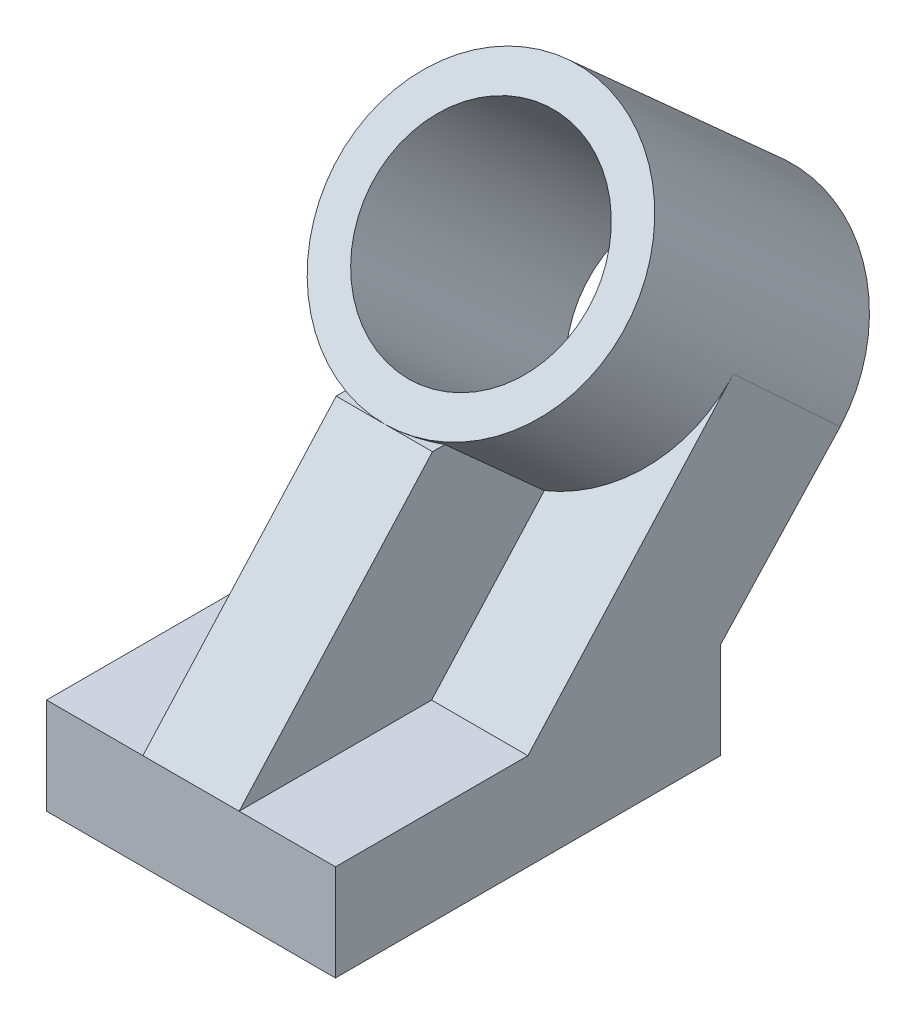
from build123d import *

# Parameters (mm, degrees)
SKETCH5_W           = 76.2
SKETCH5_H           = 101.6
BOSS_EXTRUDE2_DEPTH = 25.4
BOSS_EXTRUDE3_DEPTH = 12.7
SKETCH8_R           = 38.1
BOSS_EXTRUDE4_DEPTH = 76.2
BOSS_EXTRUDE7_DEPTH = 76.2
SKETCH11_R          = 28.575
CUT_EXTRUDE3_DEPTH  = 135.861020279


with BuildPart() as part:
    # Sketch5 → Boss-Extrude2 (new body)
    with BuildSketch(Plane(origin=(0, 0, 0), x_dir=(1, 0, 0), z_dir=(0, 1, 0))):
        with Locations((0, 0.042847785)):
            Rectangle(SKETCH5_W, SKETCH5_H)
    extrude(amount=-BOSS_EXTRUDE2_DEPTH)

    # Sketch7 → Boss-Extrude3 (add, symmetric)
    with BuildSketch(Plane(origin=(0, 0, 0), x_dir=(0, 0, -1), z_dir=(1, 0, 0))):
        Polygon((-50.757152215, 0), (0.23059999, 56.627635701), (50.987752205, 56.627635701), (0, 0), align=None)
    extrude(amount=BOSS_EXTRUDE3_DEPTH, both=True)

    # Sketch8 → Boss-Extrude4 (add)
    with BuildSketch(Plane(origin=(0, 25.239549612, 28.031359668), x_dir=(1, 0, 0), z_dir=(0, 0.669130606, 0.743144825))):
        with Locations((0, 80.336835961)):
            Circle(SKETCH8_R)
    extrude(amount=-BOSS_EXTRUDE4_DEPTH)

    # Sketch14 → Boss-Extrude7 (add, through all)
    with BuildSketch(Plane(origin=(38.1, 0, 0), x_dir=(0, 0, -1), z_dir=(1, 0, 0))):
        Polygon((82.352111793, 33.953701348), (50.842847785, 0), (0, 0), (50.664048261, 56.26812605), (54.200329047, 60.078745736), align=None)
    extrude(amount=-BOSS_EXTRUDE7_DEPTH)

    # Sketch11 → Cut-Extrude3 (cut, through all)
    with BuildSketch(Plane(origin=(0, 25.239549612, 28.031359668), x_dir=(1, 0, 0), z_dir=(0, 0.669130606, 0.743144825))):
        with Locations((0, 80.336835961)):
            Circle(SKETCH11_R)
    extrude(amount=-CUT_EXTRUDE3_DEPTH, mode=Mode.SUBTRACT)


solid = part.part
